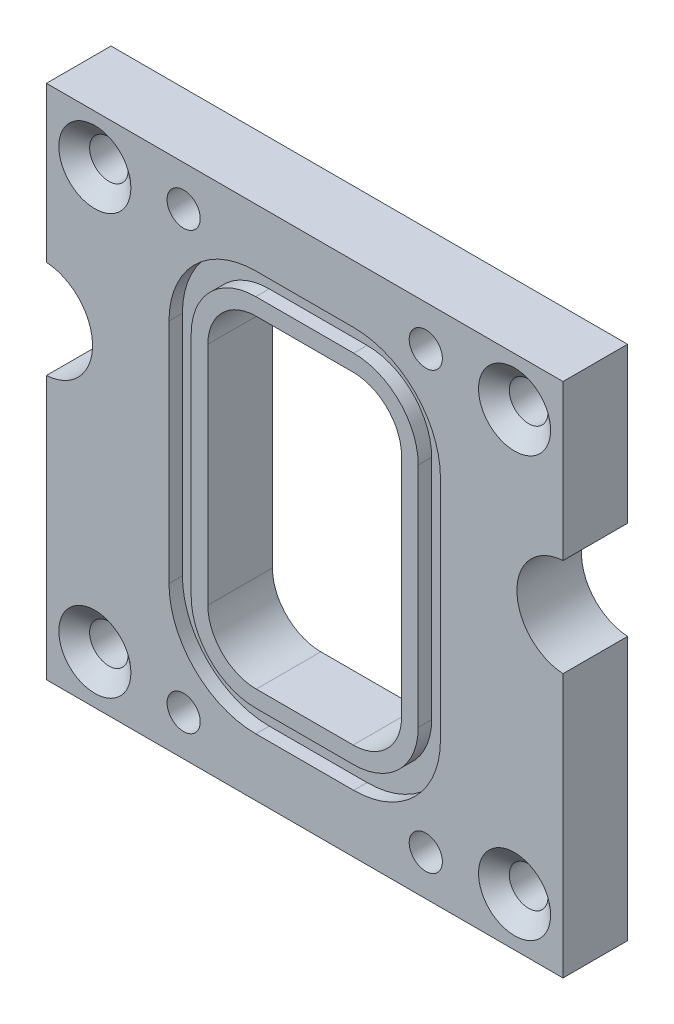
from build123d import *

# Parameters (mm, degrees)
SKETCH1_W                                         = 50.8
SKETCH1_H                                         = 50.8
BOSS_EXTRUDE1_DEPTH                               = 6.35
CUT_EXTRUDE1_DEPTH                                = 7.35
CUT_EXTRUDE2_DASH_027_DEPTH                       = 1.3208
CSK_FOR_6_FLAT_HEAD_MACHINE_SCREW_100_D           = 3.7973
CSK_FOR_6_FLAT_HEAD_MACHINE_SCREW_100_CSINK_D     = 7.0866
CSK_FOR_6_FLAT_HEAD_MACHINE_SCREW_100_CSINK_ANGLE = 100
CSK_FOR_4_FLAT_HEAD_MACHINE_SCREW_100_D           = 3.2639
CSK_FOR_4_FLAT_HEAD_MACHINE_SCREW_100_CSINK_D     = 6.477
CSK_FOR_4_FLAT_HEAD_MACHINE_SCREW_100_CSINK_ANGLE = 82
SKETCH8_R                                         = 4.826
CUT_EXTRUDE2_DEPTH                                = 7.35


with BuildPart() as part:
    # Sketch1 → Boss-Extrude1 (new body)
    with BuildSketch(Plane.XY):
        Rectangle(SKETCH1_W, SKETCH1_H)
    extrude(amount=BOSS_EXTRUDE1_DEPTH)

    # Sketch2 → Cut-Extrude1 (cut, through all)
    with BuildSketch(Plane.XY.offset(6.35)):
        with BuildLine():
            Line((-4.7625, -15.875), (4.7625, -15.875))
            ThreePointArc((4.7625, -15.875), (8.130096045, -14.480096045), (9.525, -11.1125))
            Line((9.525, -11.1125), (9.525, 11.1125))
            ThreePointArc((9.525, 11.1125), (8.130096045, 14.480096045), (4.7625, 15.875))
            Line((4.7625, 15.875), (-4.7625, 15.875))
            ThreePointArc((-4.7625, 15.875), (-8.130096045, 14.480096045), (-9.525, 11.1125))
            Line((-9.525, 11.1125), (-9.525, -11.1125))
            ThreePointArc((-9.525, -11.1125), (-8.130096045, -14.480096045), (-4.7625, -15.875))
        make_face()
    extrude(amount=-CUT_EXTRUDE1_DEPTH, mode=Mode.SUBTRACT)

    # Sketch3 → Cut-Extrude2 - dash 027 (cut)
    with BuildSketch(Plane.XY.offset(6.35)):
        with BuildLine():
            Line((13.3477, -11.176), (13.3477, 11.176))
            ThreePointArc((13.3477, 11.176), (10.848032113, 17.210732113), (4.8133, 19.7104))
            Line((4.8133, 19.7104), (-4.8133, 19.7104))
            ThreePointArc((-4.8133, 19.7104), (-10.848032113, 17.210732113), (-13.3477, 11.176))
            Line((-13.3477, 11.176), (-13.3477, -11.176))
            ThreePointArc((-13.3477, -11.176), (-10.848032113, -17.210732113), (-4.8133, -19.7104))
            Line((-4.8133, -19.7104), (4.8133, -19.7104))
            ThreePointArc((4.8133, -19.7104), (10.848032113, -17.210732113), (13.3477, -11.176))
        make_face()
        with BuildLine():
            Line((-4.8133, -17.526), (4.8133, -17.526))
            ThreePointArc((4.8133, -17.526), (9.303428061, -15.666128061), (11.1633, -11.176))
            Line((11.1633, -11.176), (11.1633, 11.176))
            ThreePointArc((11.1633, 11.176), (9.303428061, 15.666128061), (4.8133, 17.526))
            Line((4.8133, 17.526), (-4.8133, 17.526))
            ThreePointArc((-4.8133, 17.526), (-9.303428061, 15.666128061), (-11.1633, 11.176))
            Line((-11.1633, 11.176), (-11.1633, -11.176))
            ThreePointArc((-11.1633, -11.176), (-9.303428061, -15.666128061), (-4.8133, -17.526))
        make_face(mode=Mode.SUBTRACT)
    cut_extrude2_dash_027 = extrude(amount=-CUT_EXTRUDE2_DASH_027_DEPTH, mode=Mode.SUBTRACT)

    # CSK for #6 Flat Head Machine Screw (100)1 (through all)
    with Locations(Plane.XY.offset(6.35)):
        with Locations((-20.6375, 20.6375), (20.6375, 20.6375), (20.6375, -20.6375), (-20.6375, -20.6375)):
            CounterSinkHole(CSK_FOR_6_FLAT_HEAD_MACHINE_SCREW_100_D / 2, CSK_FOR_6_FLAT_HEAD_MACHINE_SCREW_100_CSINK_D / 2, counter_sink_angle=CSK_FOR_6_FLAT_HEAD_MACHINE_SCREW_100_CSINK_ANGLE)

    # CSK for #4 Flat Head Machine Screw (100)1 (through all)
    with Locations(Plane(origin=(0, 0, 0), x_dir=(-1, 0, 0), z_dir=(0, 0, -1))):
        with Locations((-11.90625, 21.43125), (11.90625, 21.43125), (-11.90625, -21.43125), (11.90625, -21.43125)):
            CounterSinkHole(CSK_FOR_4_FLAT_HEAD_MACHINE_SCREW_100_D / 2, CSK_FOR_4_FLAT_HEAD_MACHINE_SCREW_100_CSINK_D / 2, counter_sink_angle=CSK_FOR_4_FLAT_HEAD_MACHINE_SCREW_100_CSINK_ANGLE)

    # Mirror1: Cut-Extrude2 - dash 027 across plane
    add(cut_extrude2_dash_027.mirror(Plane(origin=(0, 0, 3.175), x_dir=(1, 0, 0), z_dir=(0, 0, -1))), mode=Mode.SUBTRACT)

    # Sketch8 → Cut-Extrude2 (cut, through all)
    with BuildSketch(Plane.XY.offset(6.35)):
        with Locations((-25.6921, 5.334)):
            Circle(SKETCH8_R)
    cut_extrude2 = extrude(amount=-CUT_EXTRUDE2_DEPTH, mode=Mode.SUBTRACT)

    # Mirror2: Cut-Extrude2 across plane
    add(cut_extrude2.mirror(Plane(origin=(0, 0, 0), x_dir=(0, 0, 1), z_dir=(1, 0, 0))), mode=Mode.SUBTRACT)


solid = part.part
